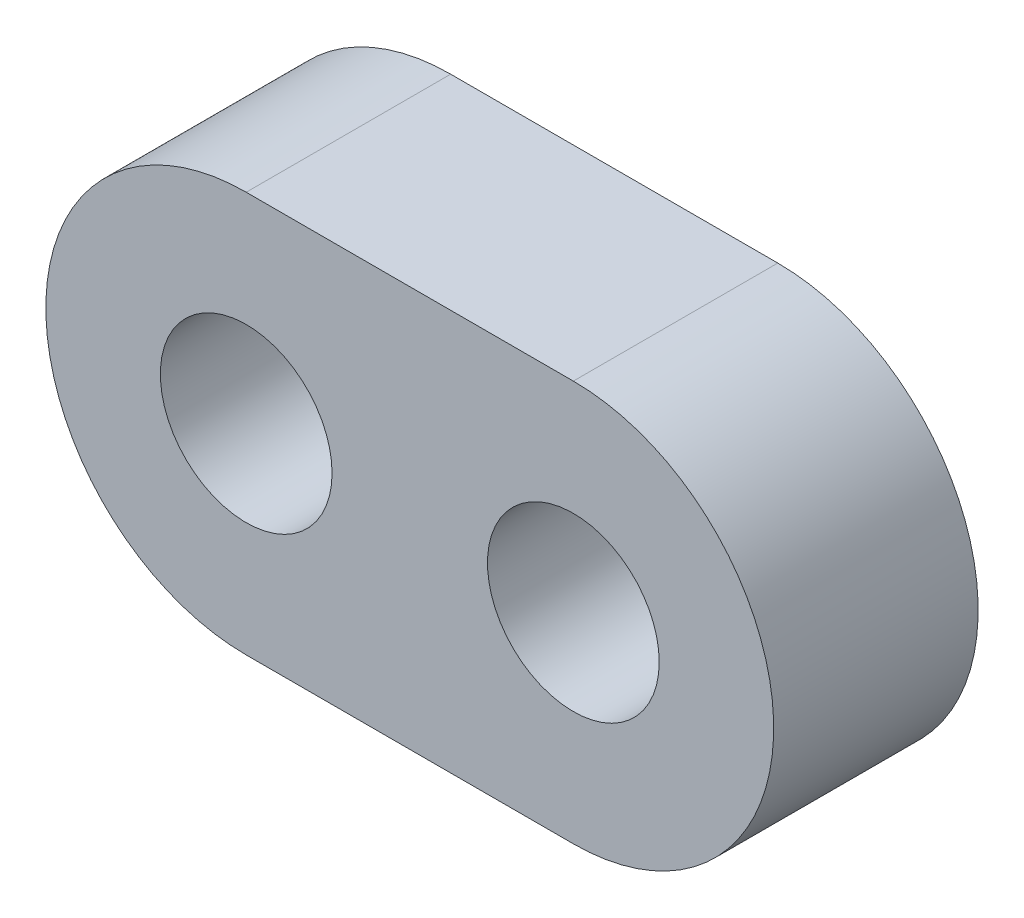
from build123d import *

# Parameters (mm, degrees)
SKETCH1_R           = 2.1
BOSS_EXTRUDE1_DEPTH = 5


with BuildPart() as part:
    # Sketch1 → Boss-Extrude1 (new body)
    with BuildSketch(Plane.XY):
        with BuildLine():
            Line((-4, 4.9), (4, 4.9))
            ThreePointArc((4, 4.9), (8.9, 0), (4, -4.9))
            Line((4, -4.9), (-4, -4.9))
            ThreePointArc((-4, -4.9), (-8.9, 0), (-4, 4.9))
        make_face()
        with Locations((-4, 0)):
            Circle(SKETCH1_R, mode=Mode.SUBTRACT)
        with Locations((4, 0)):
            Circle(SKETCH1_R, mode=Mode.SUBTRACT)
    extrude(amount=BOSS_EXTRUDE1_DEPTH)


solid = part.part
